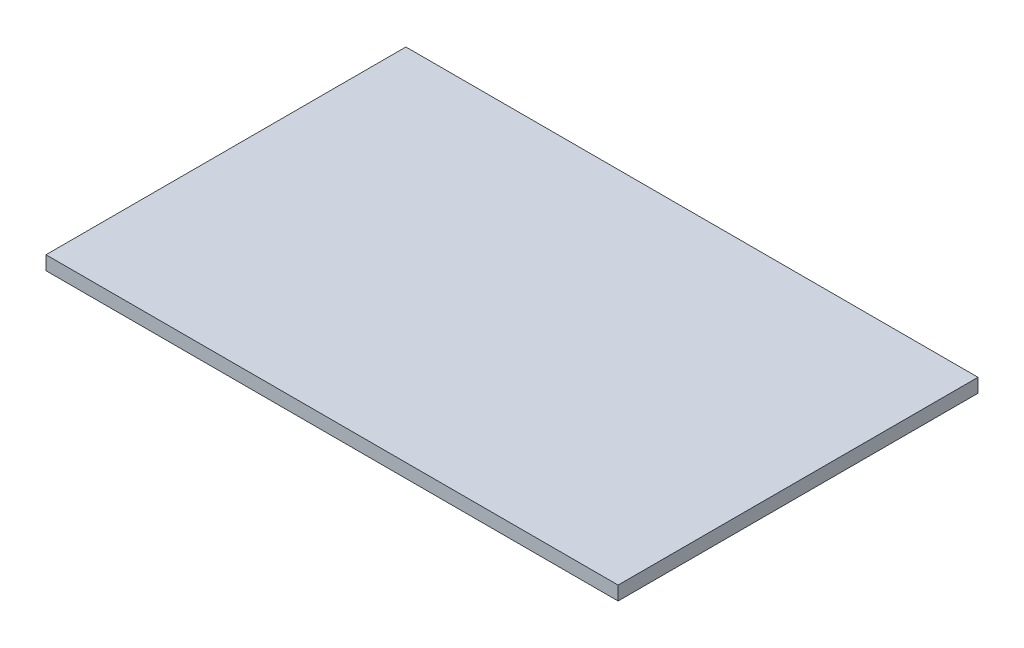
from build123d import *

# Parameters (mm, degrees)
SKETCH1_W           = 787.4
SKETCH1_H           = 495.3
BOSS_EXTRUDE1_DEPTH = 19.05


with BuildPart() as part:
    # Sketch1 → Boss-Extrude1 (new body)
    with BuildSketch(Plane(origin=(0, 0, 0), x_dir=(1, 0, 0), z_dir=(0, 1, 0))):
        with Locations((393.7, 247.65)):
            Rectangle(SKETCH1_W, SKETCH1_H)
    extrude(amount=BOSS_EXTRUDE1_DEPTH)


solid = part.part
